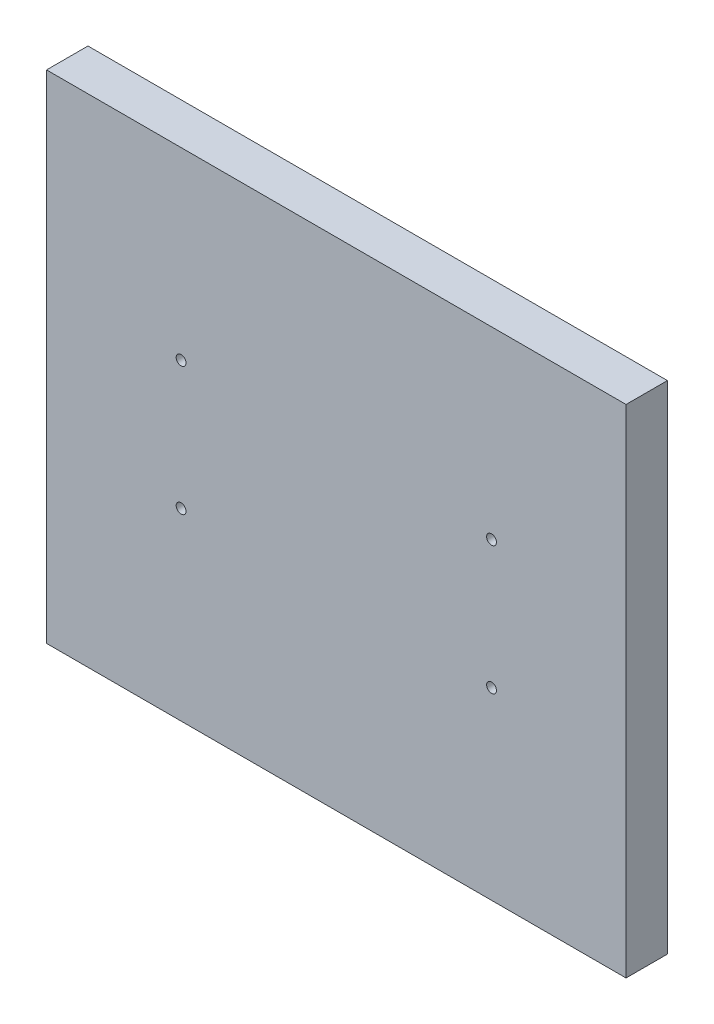
from build123d import *

# Parameters (mm, degrees)
SKETCH1_W                 = 140
SKETCH1_H                 = 120
BOSS_EXTRUDE1_DEPTH       = 10
F_4_48_TAPPED_HOLE1_D     = 2.3749
F_4_48_TAPPED_HOLE1_DEPTH = 7.27
F_4_48_TAPPED_HOLE1_TIP   = 0.713491942


with BuildPart() as part:
    # Sketch1 → Boss-Extrude1 (new body)
    with BuildSketch(Plane.XY):
        Rectangle(SKETCH1_W, SKETCH1_H)
    extrude(amount=BOSS_EXTRUDE1_DEPTH)

    # #4-48 Tapped Hole1
    with Locations(Plane.XY.offset(10)):
        with Locations((-37.5, 15.5), (-37.5, -15.5), (37.5, 15.5), (37.5, -15.5)):
            Hole(F_4_48_TAPPED_HOLE1_D / 2, depth=F_4_48_TAPPED_HOLE1_DEPTH)
            with Locations((0, 0, -(F_4_48_TAPPED_HOLE1_DEPTH + F_4_48_TAPPED_HOLE1_TIP / 2))):  # 118° drill point
                Cone(0, F_4_48_TAPPED_HOLE1_D / 2, F_4_48_TAPPED_HOLE1_TIP, mode=Mode.SUBTRACT)


solid = part.part
